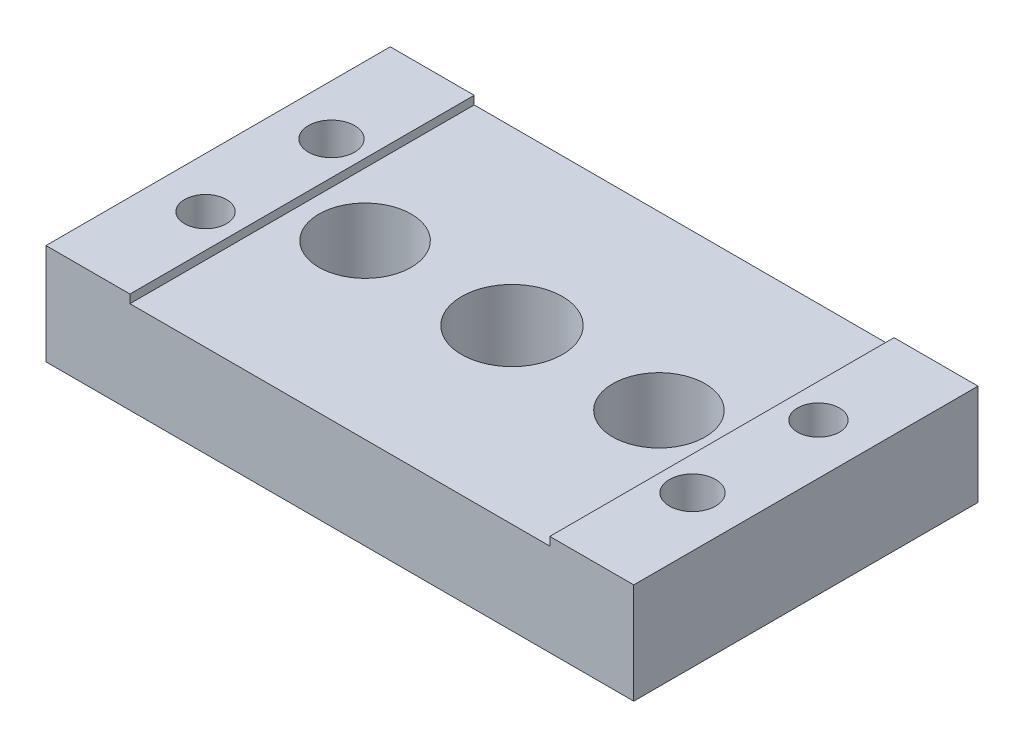
from build123d import *

# Parameters (mm, degrees)
SKETCH1_W           = 70
SKETCH1_H           = 41
BOSS_EXTRUDE1_DEPTH = 12
SKETCH2_W           = 50
SKETCH2_H           = 1
CUT_EXTRUDE1_DEPTH  = 88
SKETCH3_R           = 2.5
SKETCH3_R_2         = 2.75
CUT_EXTRUDE2_DEPTH  = 88
SKETCH4_R           = 5
CUT_EXTRUDE3_DEPTH  = 5.7
SKETCH5_R           = 2.5
CUT_EXTRUDE4_DEPTH  = 12
SKETCH6_R           = 6
SKETCH6_R_2         = 5.5
CUT_EXTRUDE5_DEPTH  = 39
SKETCH8_R           = 2.5
BOSS_EXTRUDE2_DEPTH = 41
SKETCH9_R           = 2.5
CUT_EXTRUDE6_DEPTH  = 12
SKETCH10_R          = 6
CUT_EXTRUDE7_DEPTH  = 30


with BuildPart() as part:
    # Sketch1 → Boss-Extrude1 (new body)
    with BuildSketch(Plane(origin=(0, 0, 0), x_dir=(1, 0, 0), z_dir=(0, 1, 0))):
        Rectangle(SKETCH1_W, SKETCH1_H)
    extrude(amount=BOSS_EXTRUDE1_DEPTH)

    # Sketch2 → Cut-Extrude1 (cut)
    with BuildSketch(Plane.XY.offset(20.5)):
        with Locations((0, 11.5)):
            Rectangle(SKETCH2_W, SKETCH2_H)
    extrude(amount=-CUT_EXTRUDE1_DEPTH, mode=Mode.SUBTRACT)

    # Sketch3 → Cut-Extrude2 (cut)
    with BuildSketch(Plane.XZ):
        with Locations((29, -7.5)):
            Circle(SKETCH3_R)
        with Locations((-29, 7.5)):
            Circle(SKETCH3_R)
        with Locations((29, 7.5)):
            Circle(SKETCH3_R_2)
        with Locations((-29, -7.5)):
            Circle(SKETCH3_R_2)
    extrude(amount=-CUT_EXTRUDE2_DEPTH, mode=Mode.SUBTRACT)

    # Sketch4 → Cut-Extrude3 (cut)
    with BuildSketch(Plane.XZ):
        with Locations((-29, -7.5)):
            Circle(SKETCH4_R)
        with Locations((29, 7.5)):
            Circle(SKETCH4_R)
    extrude(amount=-CUT_EXTRUDE3_DEPTH, mode=Mode.SUBTRACT)

    # Sketch5 → Cut-Extrude4 (cut)
    with BuildSketch(Plane(origin=(0, 0, -20.5), x_dir=(-1, 0, 0), z_dir=(0, 0, -1))):
        with Locations((-6.5, 6)):
            Circle(SKETCH5_R)
    extrude(amount=-CUT_EXTRUDE4_DEPTH, mode=Mode.SUBTRACT)

    # Sketch6 → Cut-Extrude5 (cut)
    with BuildSketch(Plane.XZ):
        Circle(SKETCH6_R)
        with Locations((-17.5, 0)):
            Circle(SKETCH6_R_2)
        with Locations((17.5, 0)):
            Circle(SKETCH6_R_2)
    extrude(amount=-CUT_EXTRUDE5_DEPTH, mode=Mode.SUBTRACT)

    # Sketch8 → Boss-Extrude2 (add)
    with BuildSketch(Plane(origin=(0, 0, -20.5), x_dir=(-1, 0, 0), z_dir=(0, 0, -1))):
        with Locations((-6.5, 6)):
            Circle(SKETCH8_R)
    extrude(amount=-BOSS_EXTRUDE2_DEPTH)

    # Sketch9 → Cut-Extrude6 (cut)
    with BuildSketch(Plane(origin=(0, 0, -20.5), x_dir=(-1, 0, 0), z_dir=(0, 0, -1))):
        with Locations((-6.5, 5.5)):
            Circle(SKETCH9_R)
    extrude(amount=-CUT_EXTRUDE6_DEPTH, mode=Mode.SUBTRACT)

    # Sketch10 → Cut-Extrude7 (cut)
    with BuildSketch(Plane(origin=(0, 11, 0), x_dir=(1, 0, 0), z_dir=(0, 1, 0))):
        Circle(SKETCH10_R)
    extrude(amount=-CUT_EXTRUDE7_DEPTH, mode=Mode.SUBTRACT)


solid = part.part
